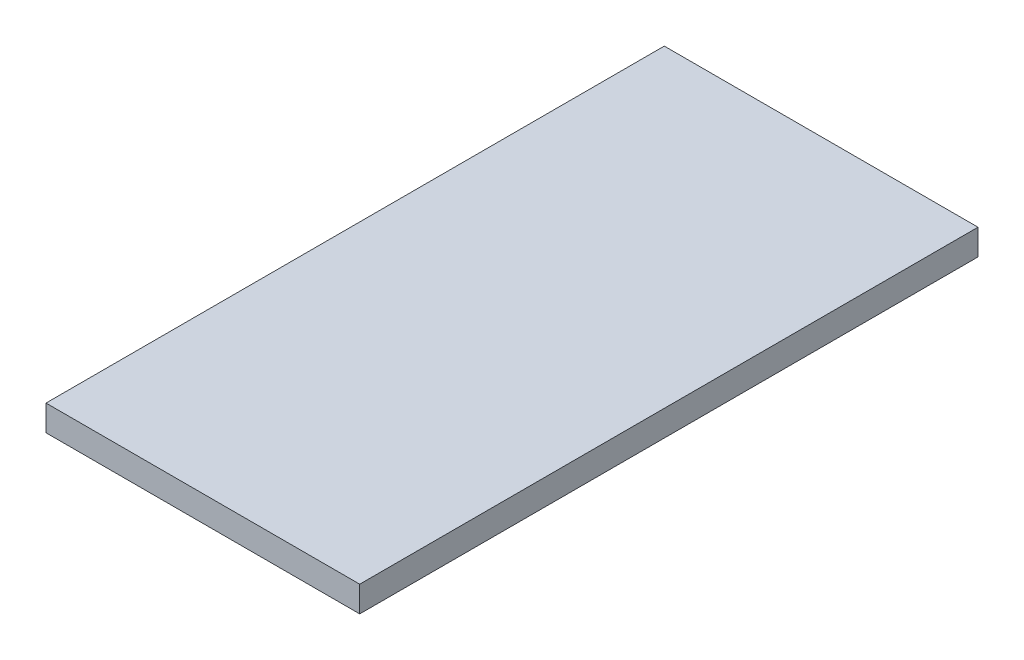
from build123d import *

# Parameters (mm, degrees)
SKETCH1_W           = 154.65
SKETCH1_H           = 12.7
BOSS_EXTRUDE1_DEPTH = 304.8


with BuildPart() as part:
    # Sketch1 → Boss-Extrude1 (new body)
    with BuildSketch(Plane.XY):
        with Locations((9.550778701, 51.05)):
            Rectangle(SKETCH1_W, SKETCH1_H)
    extrude(amount=-BOSS_EXTRUDE1_DEPTH)


solid = part.part
